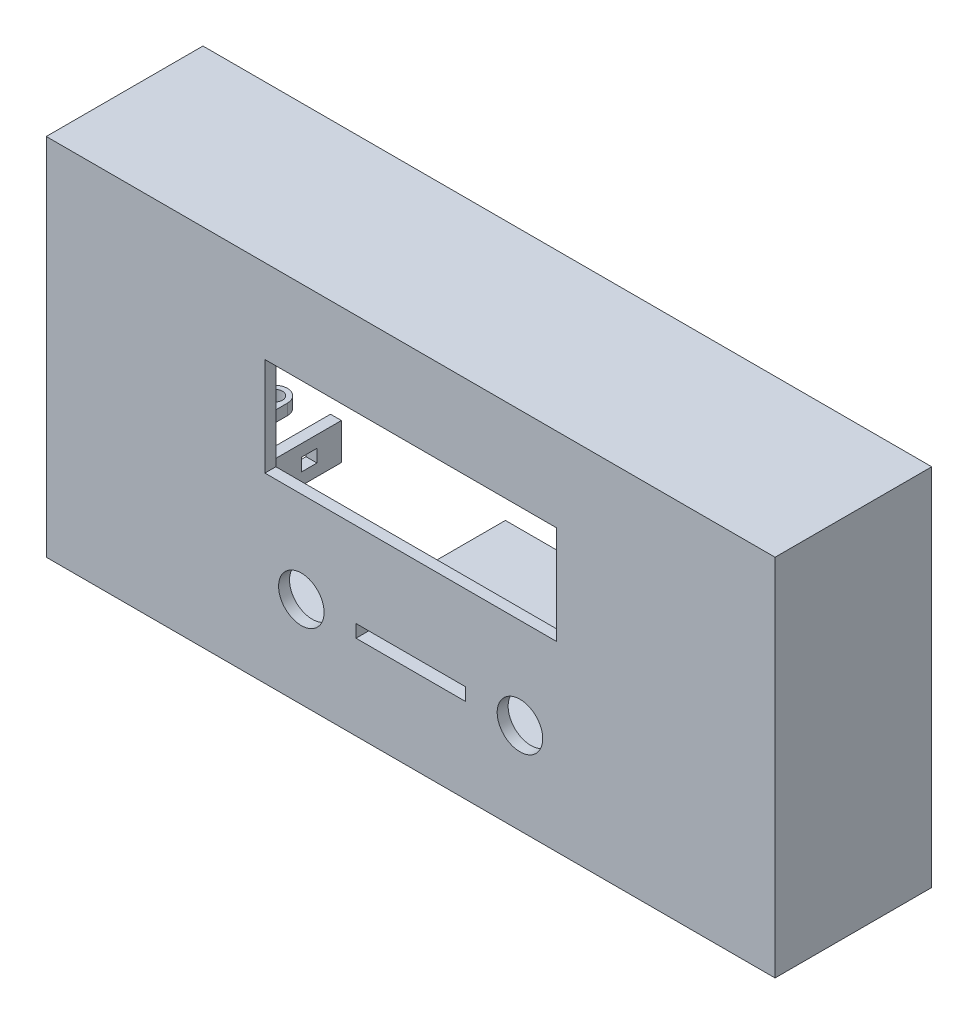
from build123d import *

# Parameters (mm, degrees)
SKETCH_1_W           = 200
SKETCH_1_H           = 100
SKETCH_1_R           = 6.25
SKETCH_1_W_2         = 80
SKETCH_1_H_2         = 27
SKETCH_1_W_3         = 30
SKETCH_1_H_3         = 3.5
EXTRUDE_1_DEPTH      = 3
SKETCH_2_R           = 3
SKETCH_2_R_2         = 1.5
EXTRUDE_2_DEPTH      = 9
SKETCH_4_W           = 200
SKETCH_4_H           = 100
SKETCH_4_W_2         = 194
SKETCH_4_H_2         = 94
SKETCH_4_W_3         = 34
SKETCH_4_H_3         = 7.5
SKETCH_4_W_4         = 30
SKETCH_4_H_4         = 3.5
EXTRUDE_3_DEPTH      = 40
SKETCH_5_W           = 14
SKETCH_5_H           = 3.5
CUT_EXTRUDE_1_DEPTH  = 3
SKETCH_6_W           = 3
SKETCH_6_H           = 10
EXTRUDE_4_DEPTH      = 40
SKETCH_7_W           = 4.25
SKETCH_7_H           = 3.5
CUT_EXTRUDE_2_DEPTH  = 5
EXTRUDE_START        = 6.75
SKETCH_9_R           = 2.125
SKETCH_9_R_2         = 4.75
EXTRUDE_5_DEPTH      = 2
EXTRUDE_5_DEPTH_BACK = 1
SKETCH_10_R          = 3
SKETCH_10_R_2        = 1.5
EXTRUDE_6_DEPTH      = 5
SKETCH_11_R          = 1.5
SKETCH_11_R_2        = 0.5
EXTRUDE_7_DEPTH      = 5
EXTRUDE_START_2      = -3
EXTRUDE_8_DEPTH      = 1
FILLET_1_R           = 2


with BuildPart() as part:
    # Эскиз1 → Бобышка-Вытянуть1 (new body)
    with BuildSketch(Plane.XY):
        with Locations((40, 0)):
            Rectangle(SKETCH_1_W, SKETCH_1_H)
        with Locations((10, -25)):
            Circle(SKETCH_1_R, mode=Mode.SUBTRACT)
        with Locations((70, -25)):
            Circle(SKETCH_1_R, mode=Mode.SUBTRACT)
        with Locations((40, 13.5)):
            Rectangle(SKETCH_1_W_2, SKETCH_1_H_2, mode=Mode.SUBTRACT)
        with Locations((40, -25)):
            Rectangle(SKETCH_1_W_3, SKETCH_1_H_3, mode=Mode.SUBTRACT)
    extrude(amount=EXTRUDE_1_DEPTH)

    # Эскиз2 → Бобышка-Вытянуть2 (add)
    with BuildSketch(Plane(origin=(0, 0, 0), x_dir=(-1, 0, 0), z_dir=(0, 0, -1))):
        with Locations(Location((-86.625, 41, 0), (0, 0, 180))):
            Circle(SKETCH_2_R)
        with Locations((-86.625, 41)):
            Circle(SKETCH_2_R_2, mode=Mode.SUBTRACT)
        with Locations(Location((-86.625, -14, 0), (0, 0, 180))):
            Circle(SKETCH_2_R)
        with Locations(Location((-86.625, -14, 0), (0, 0, 180))):
            Circle(SKETCH_2_R_2, mode=Mode.SUBTRACT)
        with Locations(Location((6.625, -14, 0), (0, 0, 180))):
            Circle(SKETCH_2_R)
        with Locations((6.625, -14)):
            Circle(SKETCH_2_R_2, mode=Mode.SUBTRACT)
        with Locations(Location((6.625, 41, 0), (0, 0, 180))):
            Circle(SKETCH_2_R)
        with Locations(Location((6.625, 41, 0), (0, 0, 180))):
            Circle(SKETCH_2_R_2, mode=Mode.SUBTRACT)
    extrude(amount=EXTRUDE_2_DEPTH)

    # Эскиз4 → Бобышка-Вытянуть3 (add)
    with BuildSketch(Plane(origin=(0, 0, 0), x_dir=(-1, 0, 0), z_dir=(0, 0, -1))):
        with Locations((-40, 0)):
            Rectangle(SKETCH_4_W, SKETCH_4_H)
        with Locations((-40, 0)):
            Rectangle(SKETCH_4_W_2, SKETCH_4_H_2, mode=Mode.SUBTRACT)
        with Locations((-40, -25)):
            Rectangle(SKETCH_4_W_3, SKETCH_4_H_3)
        with Locations((-40, -25)):
            Rectangle(SKETCH_4_W_4, SKETCH_4_H_4, mode=Mode.SUBTRACT)
    extrude(amount=EXTRUDE_3_DEPTH)

    # Эскиз5 → Вырез-Вытянуть1 (cut)
    with BuildSketch(Plane.ZY.offset(-23)):
        with Locations((-31, -25)):
            Rectangle(SKETCH_5_W, SKETCH_5_H)
    extrude(amount=-CUT_EXTRUDE_1_DEPTH, mode=Mode.SUBTRACT)

    # Эскиз6 → Бобышка-Вытянуть4 (add)
    with BuildSketch(Plane(origin=(0, 0, 0), x_dir=(-1, 0, 0), z_dir=(0, 0, -1))):
        with Locations((23.5, -25)):
            Rectangle(SKETCH_6_W, SKETCH_6_H)
    extrude(amount=EXTRUDE_4_DEPTH)

    # Эскиз7 → Вырез-Вытянуть2 (cut)
    with BuildSketch(Plane.ZY.offset(25)):
        with Locations((-31.165446486, -25)):
            Rectangle(SKETCH_7_W, SKETCH_7_H)
    extrude(amount=-CUT_EXTRUDE_2_DEPTH, mode=Mode.SUBTRACT)

    # Эскиз9 → Бобышка-Вытянуть5 (add, two sides)
    with BuildSketch(Plane(origin=(0, -26.75, 0), x_dir=(1, 0, 0), z_dir=(0, 1, 0)).offset(EXTRUDE_START)) as extrude_5_sk:
        with BuildLine():
            Line((-31.538318399, 34.739296559), (-31.538318399, 0))
            Line((-31.538318399, 0), (-57, 0))
            Line((-57, 0), (-57, 34.739296559))
            Line((-57, 34.739296559), (-38.538318399, 34.739296559))
            ThreePointArc((-38.538318399, 34.739296559), (-37.513192133, 37.214170293), (-35.038318399, 38.239296559))
            ThreePointArc((-35.038318399, 38.239296559), (-32.563444665, 37.214170293), (-31.538318399, 34.739296559))
        make_face()
        with Locations(Location((-49.562204657, 3.1758428, 0), (0, 0, 90))):
            Circle(SKETCH_9_R, mode=Mode.SUBTRACT)
        with Locations(Location((-35.038318399, 34.739296559, 0), (0, 0, 90))):
            Circle(SKETCH_9_R, mode=Mode.SUBTRACT)
        with Locations(Location((-49, 22.040446486, 0), (0, 0, 90))):
            Circle(SKETCH_9_R_2, mode=Mode.SUBTRACT)
    extrude(amount=EXTRUDE_5_DEPTH)
    extrude(extrude_5_sk.sketch, amount=-EXTRUDE_5_DEPTH_BACK)

    # Эскиз10 → Бобышка-Вытянуть6 (add)
    with BuildSketch(Plane(origin=(0, 0, 0), x_dir=(-1, 0, 0), z_dir=(0, 0, -1))):
        with Locations(Location((50, 10, 0), (0, 0, 180))):
            Circle(SKETCH_10_R)
        with Locations((50, 10)):
            Circle(SKETCH_10_R_2, mode=Mode.SUBTRACT)
        with Locations(Location((23, 10, 0), (0, 0, 180))):
            Circle(SKETCH_10_R)
        with Locations((23, 10)):
            Circle(SKETCH_10_R_2, mode=Mode.SUBTRACT)
        with Locations(Location((23, 40, 0), (0, 0, 180))):
            Circle(SKETCH_10_R)
        with Locations((23, 40)):
            Circle(SKETCH_10_R_2, mode=Mode.SUBTRACT)
        with Locations(Location((50, 40, 0), (0, 0, 180))):
            Circle(SKETCH_10_R)
        with Locations((50, 40)):
            Circle(SKETCH_10_R_2, mode=Mode.SUBTRACT)
    extrude(amount=EXTRUDE_6_DEPTH)

    # Эскиз11 → Бобышка-Вытянуть7 (add)
    with BuildSketch(Plane(origin=(0, 0, 0), x_dir=(-1, 0, 0), z_dir=(0, 0, -1))):
        with Locations(Location((-120.5, 35.5, 0), (0, 0, 180))):
            Circle(SKETCH_11_R)
        with Locations((-120.5, 35.5)):
            Circle(SKETCH_11_R_2, mode=Mode.SUBTRACT)
        with Locations(Location((-105.15, 35.5, 0), (0, 0, 180))):
            Circle(SKETCH_11_R)
        with Locations((-105.15, 35.5)):
            Circle(SKETCH_11_R_2, mode=Mode.SUBTRACT)
        with Locations(Location((-105.15, -5.5, 0), (0, 0, 180))):
            Circle(SKETCH_11_R)
        with Locations((-105.15, -5.5)):
            Circle(SKETCH_11_R_2, mode=Mode.SUBTRACT)
        with Locations(Location((-120.5, -5.5, 0), (0, 0, 180))):
            Circle(SKETCH_11_R)
        with Locations((-120.5, -5.5)):
            Circle(SKETCH_11_R_2, mode=Mode.SUBTRACT)
    extrude(amount=EXTRUDE_7_DEPTH)

    # Эскиз12 → Бобышка-Вытянуть8 (add)
    with BuildSketch(Plane(origin=(0, 0, -40), x_dir=(-1, 0, 0), z_dir=(0, 0, -1)).offset(EXTRUDE_START_2)):
        with BuildLine():
            Line((-140, 40), (-140, 50))
            Line((-140, 50), (-130, 50))
            ThreePointArc((-130, 50), (-132.928932188, 42.928932188), (-140, 40))
        make_face()
        with BuildLine():
            Line((60, 40), (60, 50))
            Line((60, 50), (50, 50))
            ThreePointArc((50, 50), (52.928932188, 42.928932188), (60, 40))
        make_face()
        with BuildLine():
            Line((60, -50), (50, -50))
            ThreePointArc((50, -50), (52.928932188, -42.928932188), (60, -40))
            Line((60, -40), (60, -50))
        make_face()
        with BuildLine():
            Line((-140, -50), (-130, -50))
            ThreePointArc((-130, -50), (-132.928932188, -42.928932188), (-140, -40))
            Line((-140, -40), (-140, -50))
        make_face()
    extrude(amount=-EXTRUDE_8_DEPTH)

    # Скругление1
    fillet_1_edges = [part.edges().sort_by_distance(p)[0] for p in [
        (137, 43.730303993, -36),
        (133.730303993, 47, -36),
        (-57, 43.730303993, -36),
        (-53.730303993, 47, -36),
        (-57, -43.730303993, -36),
        (-53.730303993, -47, -36),
        (133.730303993, -47, -36),
        (137, -43.730303993, -36),
    ]]
    fillet(fillet_1_edges, radius=FILLET_1_R)


solid = part.part
